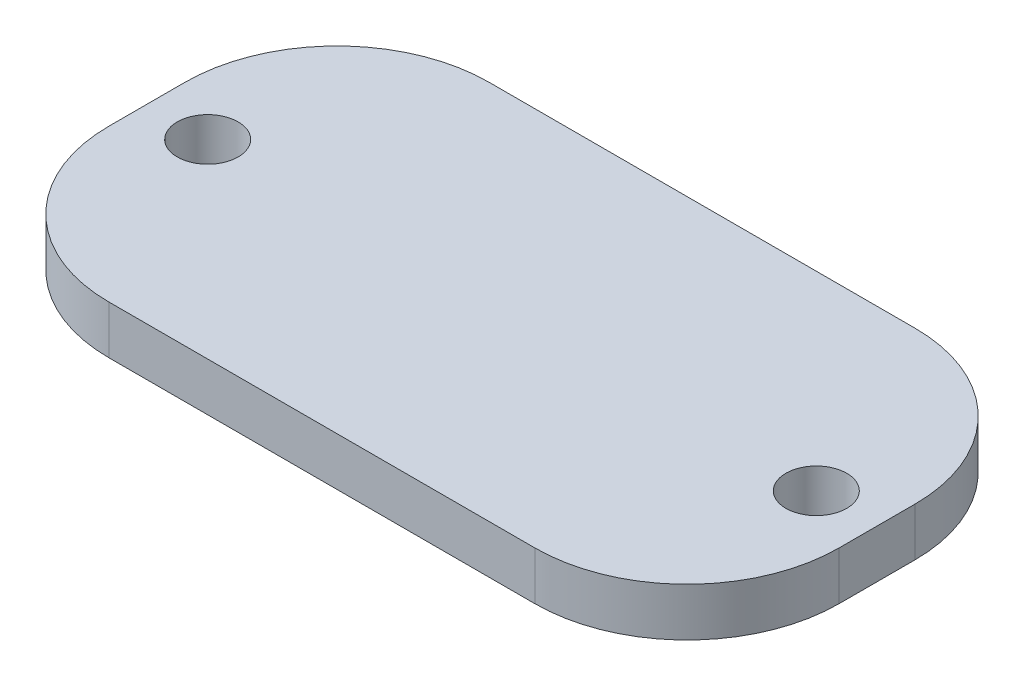
from build123d import *

# Parameters (mm, degrees)
SKETCH1_W           = 48
SKETCH1_H           = 25
SKETCH1_R           = 2
BOSS_EXTRUDE1_DEPTH = 3.175
FILLET1_R           = 10


with BuildPart() as part:
    # Sketch1 → Boss-Extrude1 (new body)
    with BuildSketch(Plane(origin=(0, 0, 0), x_dir=(1, 0, 0), z_dir=(0, 1, 0))):
        Rectangle(SKETCH1_W, SKETCH1_H)
        with Locations((-20, 0)):
            Circle(SKETCH1_R, mode=Mode.SUBTRACT)
        with Locations((20, 0)):
            Circle(SKETCH1_R, mode=Mode.SUBTRACT)
    extrude(amount=BOSS_EXTRUDE1_DEPTH)

    # Fillet1
    fillet1_edges = [part.edges().sort_by_distance(p)[0] for p in [
        (24, 1.5875, 12.5),
        (-24, 1.5875, 12.5),
        (-24, 1.5875, -12.5),
        (24, 1.5875, -12.5),
    ]]
    fillet(fillet1_edges, radius=FILLET1_R)


solid = part.part
